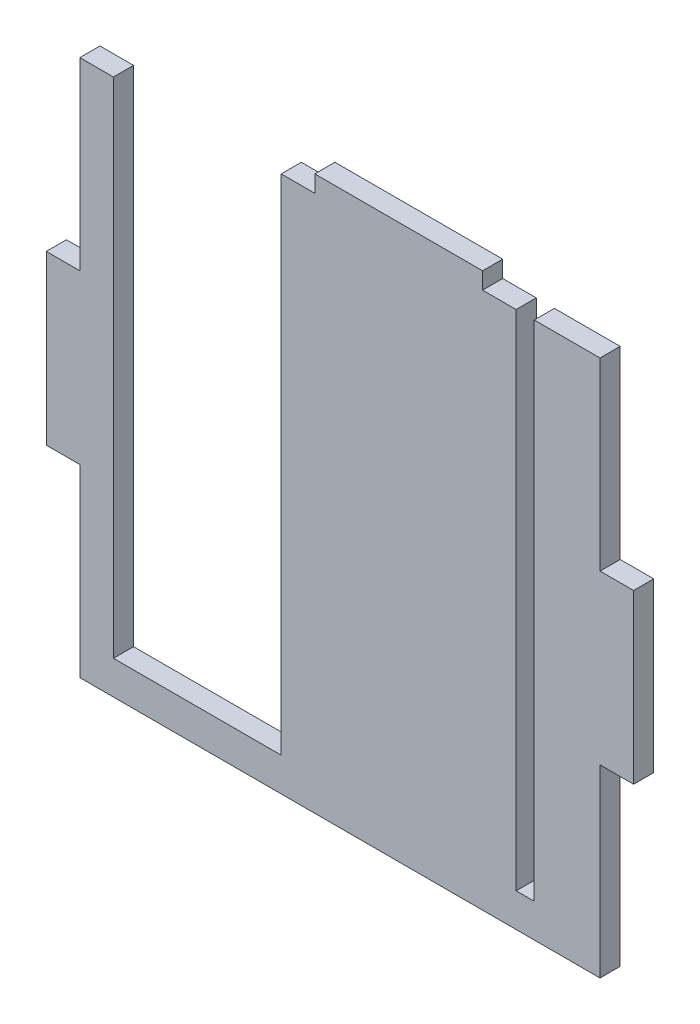
from build123d import *

# Parameters (mm, degrees)
SKETCH1_W           = 10
SKETCH1_H           = 50
SKETCH1_W_2         = 50
SKETCH1_H_2         = 5
BOSS_EXTRUDE1_DEPTH = 6


with BuildPart() as part:
    # Sketch1 → Boss-Extrude1 (new body)
    with BuildSketch(Plane.XY):
        Polygon((-155, 0), (0, 0), (0, 55), (0, 105), (0, 160), (-19.6, 160), (-19.6, 10), (-25, 10), (-25, 160), (-35, 160), (-72.61115591, 160), (-77.64696312, 160), (-85, 160), (-95, 160), (-95, 10), (-145, 10), (-145, 160), (-155, 160), (-155, 105), (-155, 55), align=None)
        with Locations((-160, 80)):
            Rectangle(SKETCH1_W, SKETCH1_H)
        with Locations((5, 80)):
            Rectangle(SKETCH1_W, SKETCH1_H)
        with Locations((-60, 162.5)):
            Rectangle(SKETCH1_W_2, SKETCH1_H_2)
    extrude(amount=BOSS_EXTRUDE1_DEPTH)


solid = part.part
